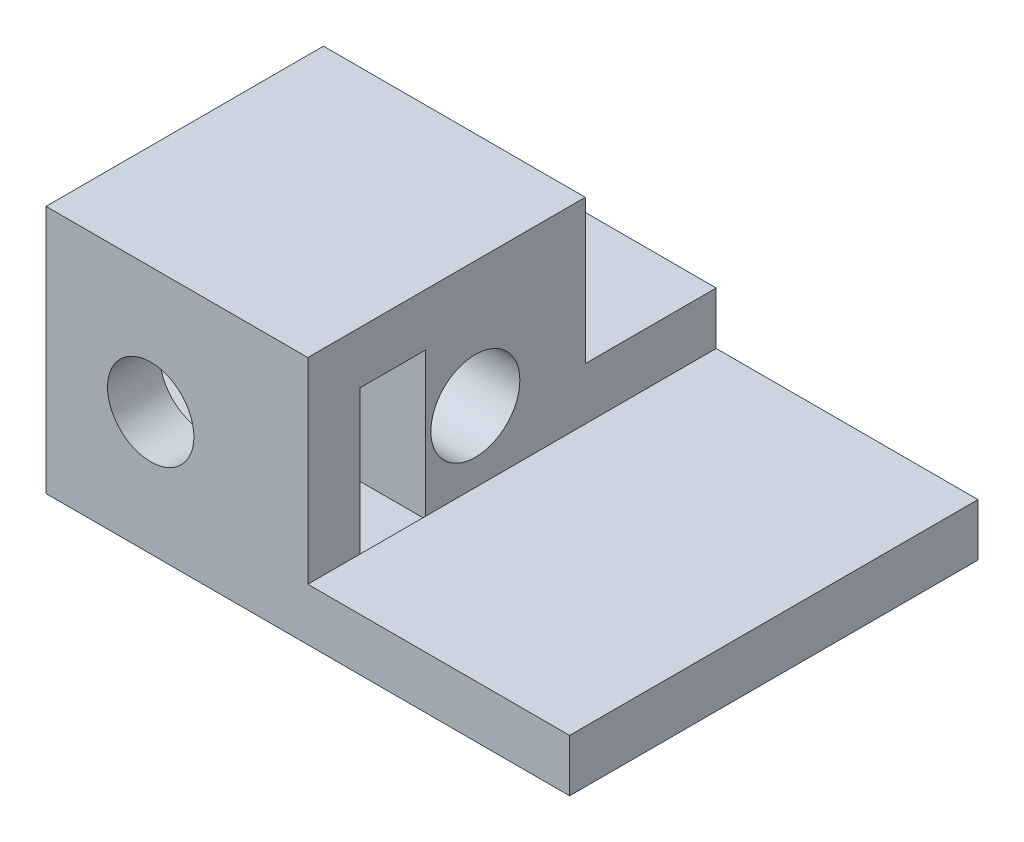
from build123d import *

# Parameters (mm, degrees)
RESSALTO_EXTRUS_O1_DEPTH             = 52.5
ESBO_O3_W                            = 10
ESBO_O3_H                            = 4
RESSALTO_EXTRUS_O2_DEPTH             = 5
ESBO_O4_R                            = 1.7
ESBO_O4_W                            = 2.5
ESBO_O4_H                            = 5.6
RESSALTO_EXTRUS_O3_DEPTH             = 10
ESBO_O5_R                            = 1.65
CORTE_EXTRUS_O1_DEPTH                = 6
RESSALTO_EXTRUS_O4_REACH             = 12.6
ESBO_O6_W                            = 10
ESBO_O6_H                            = 2
RESSALTO_EXTRUS_O4_DIRECTION_2_REACH = 117.6
ESBO_O7_W                            = 20
ESBO_O7_H                            = 110.6
CORTE_EXTRUS_O2_DEPTH                = 6.5
CORTE_EXTRUS_O2_DEPTH_BACK           = 5


with BuildPart() as part:
    # Esboço1 → Ressalto-extrusão1 (new body, symmetric)
    with BuildSketch(Plane.XY):
        Polygon((0, 0), (0, 2), (5, 2), (5, 4), (10, 4), (10, 2), (20, 2), (20, 0), align=None)
    extrude(amount=RESSALTO_EXTRUS_O1_DEPTH, both=True)

    # Esboço3 → Ressalto-extrusão2 (add)
    with BuildSketch(Plane.XY.offset(52.5)):
        with Locations((5, 2)):
            Rectangle(ESBO_O3_W, ESBO_O3_H)
    extrude(amount=-RESSALTO_EXTRUS_O2_DEPTH)

    # Esboço4 → Ressalto-extrusão3 (add, through all)
    with BuildSketch(Plane(origin=(10, 0, 0), x_dir=(0, 0, -1), z_dir=(1, 0, 0))):
        Polygon((-52.5, 9.5), (-63.1, 9.5), (-63.1, 0), (-52.5, 0), (-52.5, 3.742943079), align=None)
        with Locations((-56.7, 4.7)):
            Circle(ESBO_O4_R, mode=Mode.SUBTRACT)
        with Locations((-59.85, 4.7)):
            Rectangle(ESBO_O4_W, ESBO_O4_H, mode=Mode.SUBTRACT)
    ressalto_extrus_o3 = extrude(amount=-RESSALTO_EXTRUS_O3_DEPTH)

    # Esboço5 → Corte-extrusão1 (cut)
    with BuildSketch(Plane.XY.offset(63.1)):
        with Locations((4, 4.7)):
            Circle(ESBO_O5_R)
    corte_extrus_o1 = extrude(amount=-CORTE_EXTRUS_O1_DEPTH, mode=Mode.SUBTRACT)

    # Espelhar1: Ressalto-extrusão3, Corte-extrusão1 across plane
    add(ressalto_extrus_o3.mirror(Plane.XY))
    add(corte_extrus_o1.mirror(Plane.XY), mode=Mode.SUBTRACT)

    # Ressalto-extrusão4: up to this face of the body (flat: up to its plane)
    ressalto_extrus_o4_end = Plane(part.part.faces().sort_by_distance((5, 9.362068858, 63.1))[0])
    # Esboço6 → Ressalto-extrusão4 (add, up to the picked face)
    with BuildSketch(Plane.XY.offset(52.5), mode=Mode.PRIVATE) as ressalto_extrus_o4_sk1:
        with Locations((15, 1)):
            Rectangle(ESBO_O6_W, ESBO_O6_H)
    ressalto_extrus_o4_tool1 = split(extrude(ressalto_extrus_o4_sk1.sketch, amount=RESSALTO_EXTRUS_O4_REACH, mode=Mode.PRIVATE), bisect_by=ressalto_extrus_o4_end, keep=Keep.BOTH, mode=Mode.PRIVATE)
    add(ressalto_extrus_o4_tool1.solids().sort_by_distance((15, 1, 52.5))[0])

    # Ressalto-extrusão4 direction 2: up to this face of the body (flat: up to its plane)
    ressalto_extrus_o4_direction_2_end = Plane(part.part.faces().sort_by_distance((5, 9.362068858, -63.1))[0])
    # Esboço6 → Ressalto-extrusão4 direction 2 (add, up to the picked face)
    with BuildSketch(Plane.XY.offset(52.5), mode=Mode.PRIVATE) as ressalto_extrus_o4_direction_2_sk1:
        with Locations((15, 1)):
            Rectangle(ESBO_O6_W, ESBO_O6_H)
    ressalto_extrus_o4_direction_2_tool1 = split(extrude(ressalto_extrus_o4_direction_2_sk1.sketch, amount=-RESSALTO_EXTRUS_O4_DIRECTION_2_REACH, mode=Mode.PRIVATE), bisect_by=ressalto_extrus_o4_direction_2_end, keep=Keep.BOTH, mode=Mode.PRIVATE)
    add(ressalto_extrus_o4_direction_2_tool1.solids().sort_by_distance((15, 1, 52.5))[0])

    # Esboço7 → Corte-extrusão2 (cut, two sides)
    with BuildSketch(Plane(origin=(0, 4, 0), x_dir=(1, 0, 0), z_dir=(0, 1, 0))) as corte_extrus_o2_sk:
        with Locations((10, 7.8)):
            Rectangle(ESBO_O7_W, ESBO_O7_H)
    extrude(amount=CORTE_EXTRUS_O2_DEPTH, mode=Mode.SUBTRACT)
    extrude(corte_extrus_o2_sk.sketch, amount=-CORTE_EXTRUS_O2_DEPTH_BACK, mode=Mode.SUBTRACT)


solid = part.part
